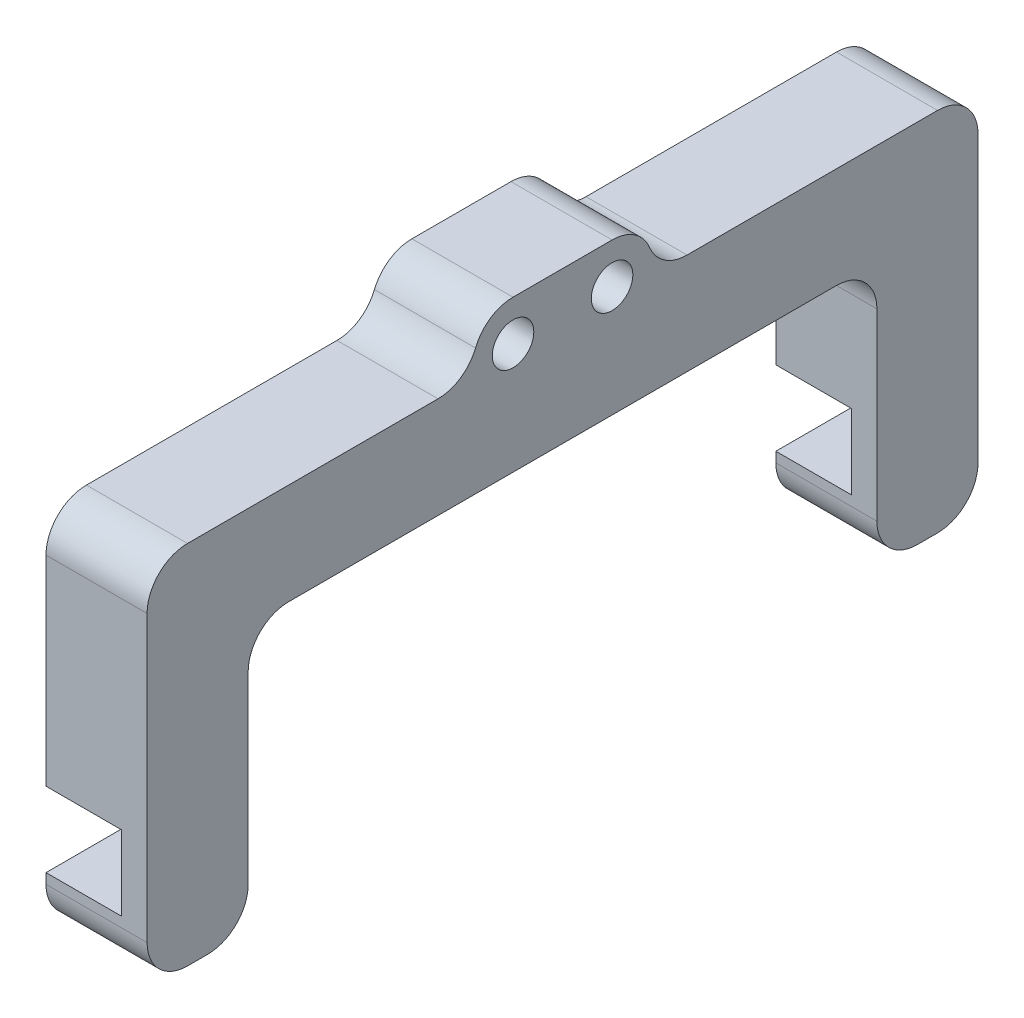
from build123d import *

# Parameters (mm, degrees)
BOSS_EXTRUDE1_DEPTH = 10
SKETCH3_R           = 2.055
CUT_EXTRUDE1_DEPTH  = 11
SKETCH5_W           = 10
SKETCH5_H           = 13.8
BOSS_EXTRUDE2_DEPTH = 10
SKETCH10_W          = 10
SKETCH10_H          = 7.4
BOSS_EXTRUDE5_DEPTH = 2.52893219
SKETCH11_W          = 10
SKETCH11_H          = 5
BOSS_EXTRUDE6_DEPTH = 10
FILLET1_R           = 4
FILLET2_R           = 4
FILLET3_R           = 4


with BuildPart() as part:
    # Sketch1 → Boss-Extrude1 (new body)
    with BuildSketch(Plane(origin=(0, 0, 0), x_dir=(0, 0, -1), z_dir=(1, 0, 0))):
        Polygon((17.8, -5), (50, -5), (50, -15), (-32.2, -15), (-32.2, -5), (0, -5), (0, 0), (17.8, 0), align=None)
    extrude(amount=BOSS_EXTRUDE1_DEPTH)

    # Sketch3 → Cut-Extrude1 (cut, through all)
    with BuildSketch(Plane(origin=(10, 0, 0), x_dir=(0, 0, -1), z_dir=(1, 0, 0))):
        with Locations((4, -4)):
            Circle(SKETCH3_R)
        with Locations((13.8, -4)):
            Circle(SKETCH3_R)
    extrude(amount=-CUT_EXTRUDE1_DEPTH, mode=Mode.SUBTRACT)

    # Sketch5 → Boss-Extrude2 (add)
    with BuildSketch(Plane(origin=(10, 0, 0), x_dir=(0, 0, -1), z_dir=(1, 0, 0))):
        with Locations((-27.2, -21.9)):
            Rectangle(SKETCH5_W, SKETCH5_H)
        with Locations((45, -21.9)):
            Rectangle(SKETCH5_W, SKETCH5_H)
    extrude(amount=-BOSS_EXTRUDE2_DEPTH)

    # Sketch10 → Boss-Extrude5 (add)
    with BuildSketch(Plane(origin=(10, 0, 0), x_dir=(0, 0, -1), z_dir=(1, 0, 0))):
        with Locations((-27.2, -32.5)):
            Rectangle(SKETCH10_W, SKETCH10_H)
    boss_extrude5 = extrude(amount=-BOSS_EXTRUDE5_DEPTH)

    # Sketch11 → Boss-Extrude6 (add)
    with BuildSketch(Plane(origin=(10, 0, 0), x_dir=(0, 0, -1), z_dir=(1, 0, 0))):
        with Locations((-27.2, -38.7)):
            Rectangle(SKETCH11_W, SKETCH11_H)
    boss_extrude6 = extrude(amount=-BOSS_EXTRUDE6_DEPTH)

    # Mirror1: Boss-Extrude5, Boss-Extrude6 across plane
    add(boss_extrude5.mirror(Plane.XY.offset(-8.9)))
    add(boss_extrude6.mirror(Plane.XY.offset(-8.9)))

    # Fillet1
    fillet1_edges = [part.edges().sort_by_distance(p)[0] for p in [
        (5, 0, 0),
        (5, 0, -17.8),
    ]]
    fillet(fillet1_edges, radius=FILLET1_R)

    # Fillet2
    fillet2_edges = [part.edges().sort_by_distance(p)[0] for p in [
        (5, -41.2, -50),
        (5, -41.2, -40),
        (5, -5, -50),
        (5, -5, 32.2),
        (5, -15, 22.2),
        (5, -15, -40),
        (5, -41.2, 22.2),
        (5, -41.2, 32.2),
    ]]
    fillet(fillet2_edges, radius=FILLET2_R)

    # Fillet3
    fillet3_edges = [part.edges().sort_by_distance(p)[0] for p in [
        (5, -5, -17.8),
        (5, -5, 0),
    ]]
    fillet(fillet3_edges, radius=FILLET3_R)


solid = part.part
